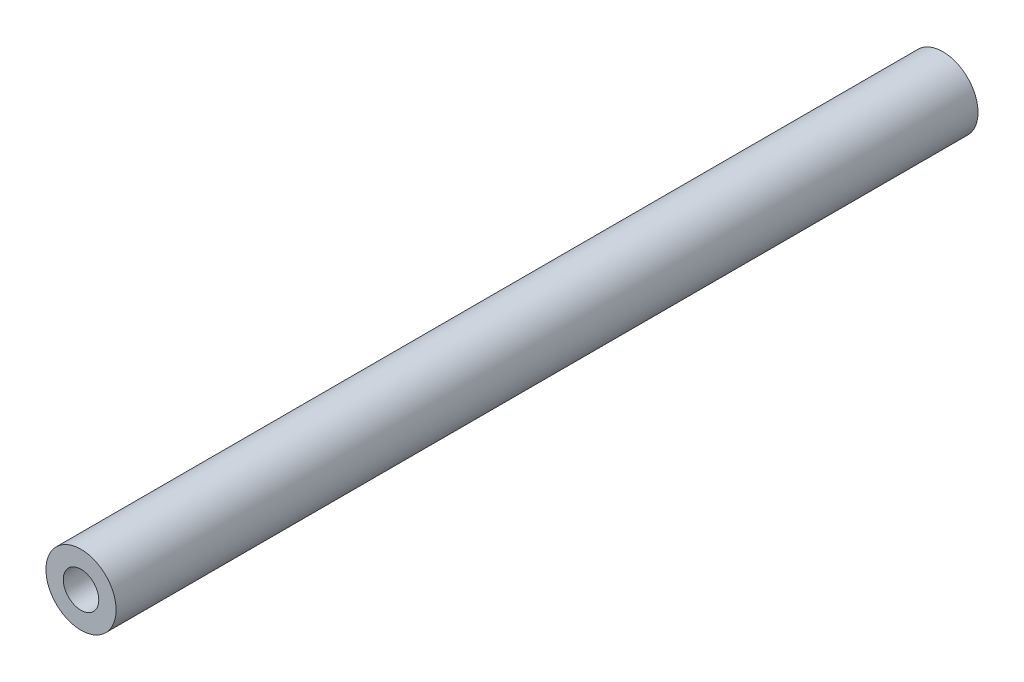
from build123d import *

# Parameters (mm, degrees)
SKETCH1_R           = 25.32728946
SKETCH1_R_2         = 12.826813773
BOSS_EXTRUDE1_DEPTH = 622.3


with BuildPart() as part:
    # Sketch1 → Boss-Extrude1 (new body)
    with BuildSketch(Plane.XY):
        Circle(SKETCH1_R)
        Circle(SKETCH1_R_2, mode=Mode.SUBTRACT)
    extrude(amount=BOSS_EXTRUDE1_DEPTH)


solid = part.part
